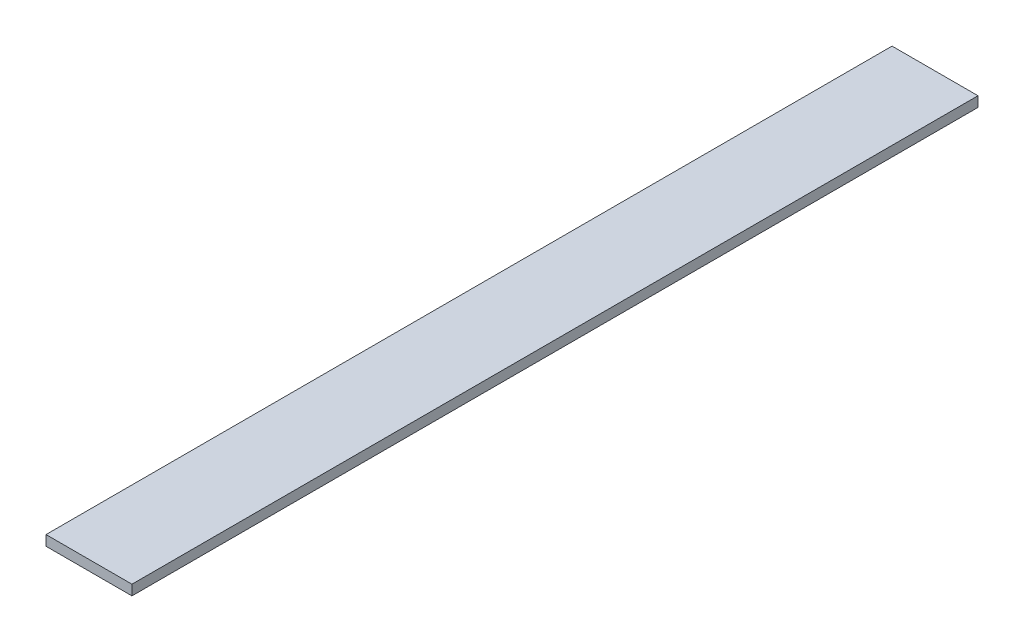
from build123d import *

# Parameters (mm, degrees)
CROQUIS1_W              = 50.8
CROQUIS1_H              = 6
SALIENTE_EXTRUIR1_DEPTH = 500


with BuildPart() as part:
    # Croquis1 → Saliente-Extruir1 (new body)
    with BuildSketch(Plane.XY):
        Rectangle(CROQUIS1_W, CROQUIS1_H)
    extrude(amount=SALIENTE_EXTRUIR1_DEPTH)


solid = part.part
